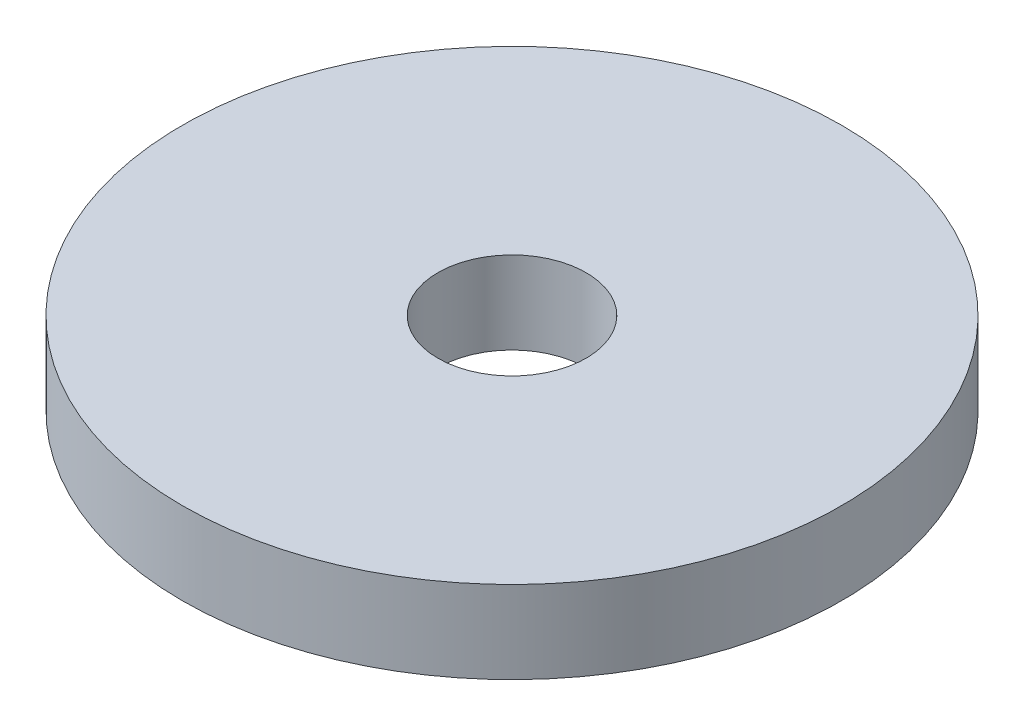
from build123d import *

# Parameters (mm, degrees)
SKETCH1_R           = 20
SKETCH1_R_2         = 4.5
BOSS_EXTRUDE1_DEPTH = 5


with BuildPart() as part:
    # Sketch1 → Boss-Extrude1 (new body)
    with BuildSketch(Plane(origin=(0, 0, 0), x_dir=(1, 0, 0), z_dir=(0, 1, 0))):
        with Locations(Location((0, 0, 0), (0, 0, 270))):  # turned: the seam where the file's is
            Circle(SKETCH1_R)
        with Locations(Location((0, 0, 0), (0, 0, 270))):  # turned: the seam where the file's is
            Circle(SKETCH1_R_2, mode=Mode.SUBTRACT)
    extrude(amount=BOSS_EXTRUDE1_DEPTH)


solid = part.part
